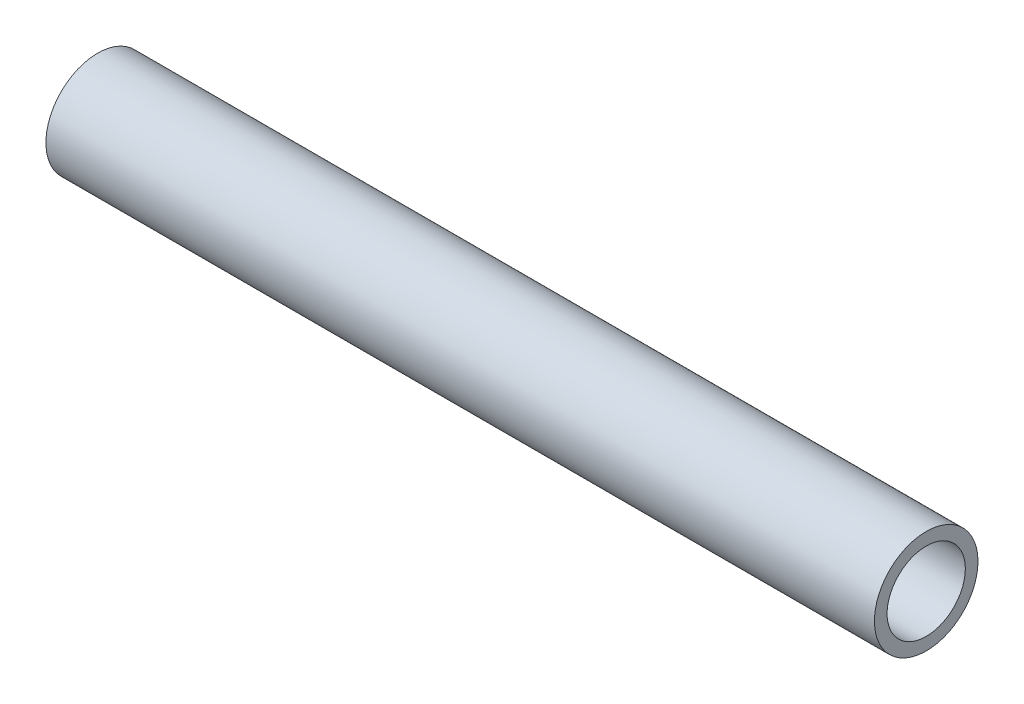
from build123d import *

# Parameters (mm, degrees)
SKETCH1_R           = 28.575
SKETCH1_R_2         = 21.59
BOSS_EXTRUDE1_DEPTH = 228.6


with BuildPart() as part:
    # Sketch1 → Boss-Extrude1 (new body, symmetric)
    with BuildSketch(Plane(origin=(0, 0, 0), x_dir=(0, 0, -1), z_dir=(1, 0, 0))):
        Circle(SKETCH1_R)
        Circle(SKETCH1_R_2, mode=Mode.SUBTRACT)
    extrude(amount=BOSS_EXTRUDE1_DEPTH, both=True)


solid = part.part
